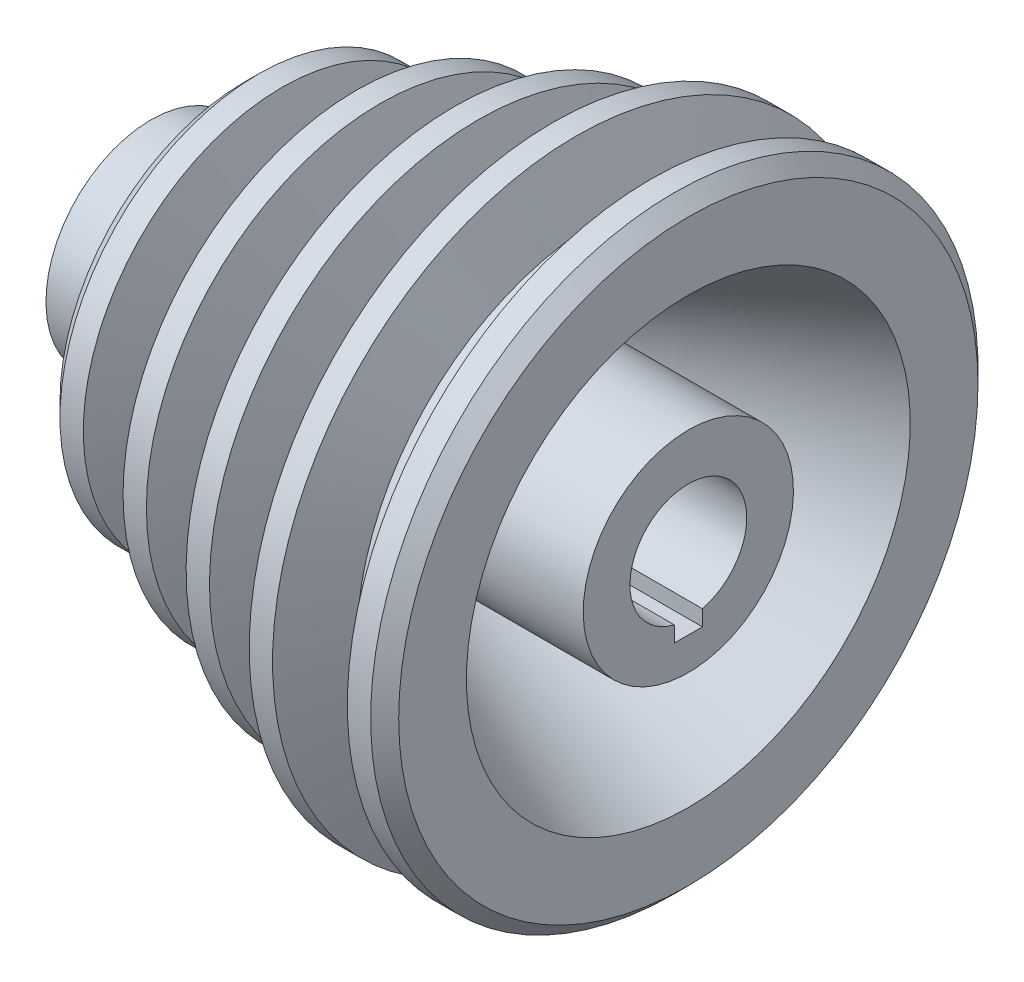
from build123d import *

# Parameters (mm, degrees)
CHAMFER1_SIZE      = 3
SKETCH2_W          = 6
SKETCH2_H          = 6
CUT_EXTRUDE1_DEPTH = 116


with BuildPart() as part:
    # Sketch1 → Revolve1 (revolve)
    with BuildSketch(Plane.XY):
        Polygon((57.5, 12.5), (-57.5, 12.5), (-57.5, 22.5), (-37.5, 22.5), (-37.5, 42.5), (-29.5, 42.5), (-24, 27.5), (-19, 27.5), (-13.5, 50), (-8.5, 50), (-3, 35), (2, 35), (7.5, 57.5), (12.5, 57.5), (18, 42.5), (23, 42.5), (28.5, 65), (33.5, 65), (39, 52.5), (44, 52.5), (49.5, 65), (57.5, 65), (57.5, 47.5), (12.5, 27.5), (12.5, 22.5), (57.5, 22.5), align=None)
    revolve(axis=Axis((57.5, 0, 0), (-1, 0, 0)))

    # Chamfer1
    chamfer1_edges = [part.edges().sort_by_distance(p)[0] for p in [
        (57.5, -65, 0),
        (-37.5, -42.5, 0),
    ]]
    chamfer(chamfer1_edges, length=CHAMFER1_SIZE)

    # Sketch2 → Cut-Extrude1 (cut, through all)
    with BuildSketch(Plane.ZY.offset(57.5)):
        with Locations((0, -12.5)):
            Rectangle(SKETCH2_W, SKETCH2_H)
    extrude(amount=-CUT_EXTRUDE1_DEPTH, mode=Mode.SUBTRACT)


solid = part.part
